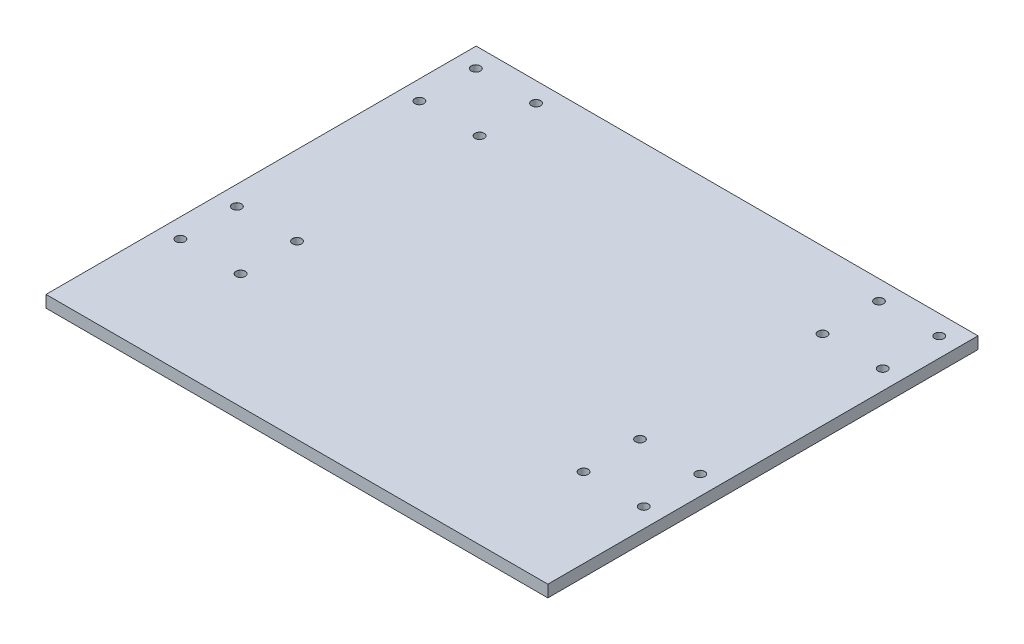
from build123d import *

# Parameters (mm, degrees)
SKETCH1_W                      = 266.7
SKETCH1_H                      = 228.6
BOSS_EXTRUDE1_DEPTH            = 6.35
M4_CLEARANCE_HOLE1_D           = 4.8
M4_CLEARANCE_HOLE1_DEPTH       = 6.35
M4_CLEARANCE_HOLE1_CSINK_D     = 4.85
M4_CLEARANCE_HOLE1_CSINK_ANGLE = 90


with BuildPart() as part:
    # Sketch1 → Boss-Extrude1 (new body)
    with BuildSketch(Plane(origin=(0, 0, 0), x_dir=(1, 0, 0), z_dir=(0, 1, 0))):
        Rectangle(SKETCH1_W, SKETCH1_H)
    extrude(amount=BOSS_EXTRUDE1_DEPTH)

    # M4 Clearance Hole1
    with Locations(Plane(origin=(0, 6.35, 0), x_dir=(1, 0, 0), z_dir=(0, 1, 0))):
        with Locations((123.125, 103.9), (91.125, 103.9), (91.125, 73.9), (123.125, -53.1), (123.125, -23.1), (123.125, 73.9), (-123.125, 103.9), (-91.125, 103.9), (-91.125, 73.9), (91.125, -53.1), (-123.125, -53.1), (-91.125, -53.1), (-91.125, -23.1), (-123.125, -23.1), (-123.125, 73.9), (91.125, -23.1)):
            CounterSinkHole(M4_CLEARANCE_HOLE1_D / 2, M4_CLEARANCE_HOLE1_CSINK_D / 2, depth=M4_CLEARANCE_HOLE1_DEPTH, counter_sink_angle=M4_CLEARANCE_HOLE1_CSINK_ANGLE)


solid = part.part
